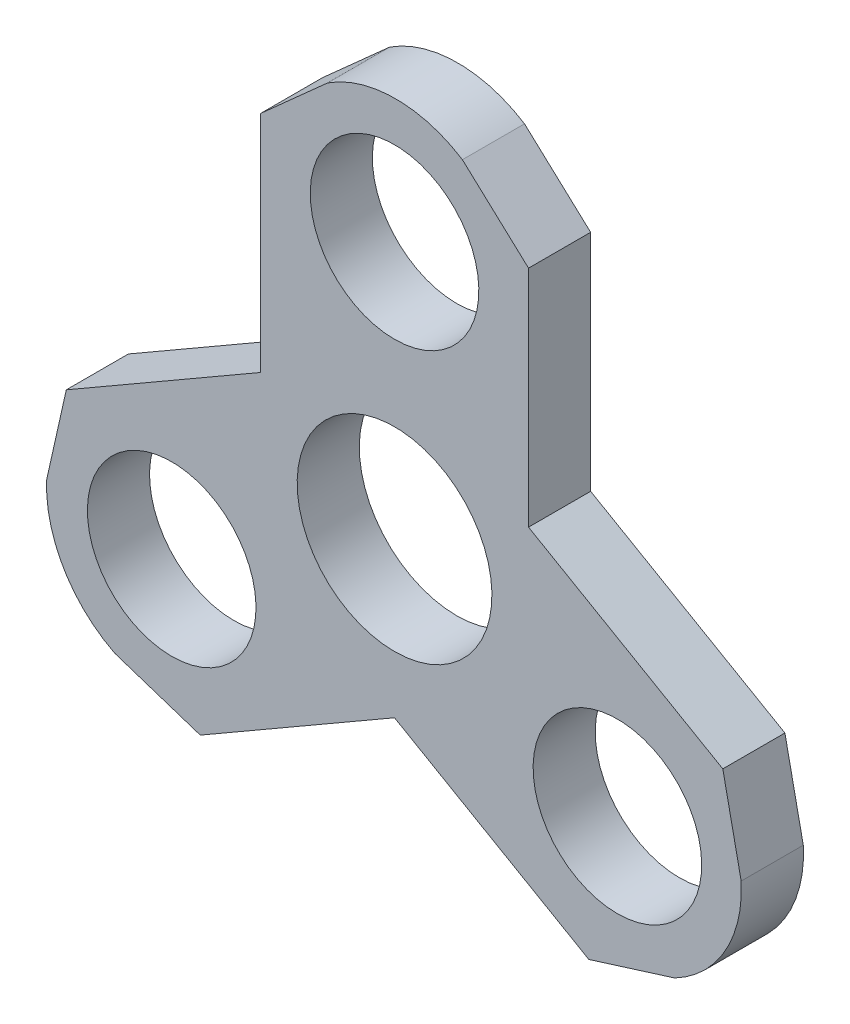
from build123d import *

# Parameters (mm, degrees)
SKETCH2_R             = 10.975
SKETCH2_R_2           = 9.5
BOSS_EXTRUDE1_DEPTH   = 7
BODY_MOVE_COPY2_ANGLE = 90


with BuildPart() as part:
    # Sketch2 → Boss-Extrude1 (new body)
    with BuildSketch(Plane(origin=(0, 0, 0), x_dir=(1, 0, 0), z_dir=(0, 1, 0))):
        with BuildLine():
            Line((15.1, 8.717989065), (15.1, 34))
            Line((15.1, 34), (7.646696155, 40.860405367))
            ThreePointArc((7.646696155, 40.860405367), (0.033272999, 43.046889297), (-7.548090014, 40.751707603))
            Line((-7.548090014, 40.751707603), (-15.1, 34))
            Line((-15.1, 34), (-15.1, 8.717989065))
            Line((-15.1, 8.717989065), (-36.994863729, -3.923016403))
            Line((-36.994863729, -3.923016403), (-39.209497135, -13.807969558))
            ThreePointArc((-39.209497135, -13.807969558), (-37.296336185, -21.494629386), (-31.517969025, -26.912691504))
            Line((-31.517969025, -26.912691504), (-21.894863729, -30.076983597))
            Line((-21.894863729, -30.076983597), (0, -17.43597813))
            Line((0, -17.43597813), (21.894863729, -30.076983597))
            Line((21.894863729, -30.076983597), (31.562800979, -27.052435809))
            ThreePointArc((31.562800979, -27.052435809), (37.263063186, -21.552259911), (39.066059039, -13.8390161))
            Line((39.066059039, -13.8390161), (36.994863729, -3.923016403))
            Line((36.994863729, -3.923016403), (15.1, 8.717989065))
        make_face()
        Circle(SKETCH2_R, mode=Mode.SUBTRACT)
        with Locations((0, 29)):
            Circle(SKETCH2_R_2, mode=Mode.SUBTRACT)
        with Locations((25.11473671, -14.5)):
            Circle(SKETCH2_R_2, mode=Mode.SUBTRACT)
        with Locations((-25.11473671, -14.5)):
            Circle(SKETCH2_R_2, mode=Mode.SUBTRACT)
    extrude(amount=BOSS_EXTRUDE1_DEPTH)


with BuildPart() as part_1:
    # Body-Move/Copy2: moved
    add(part.part.rotate(Axis((0, 3.5, -6.485131953), (1, 0, 0)), BODY_MOVE_COPY2_ANGLE))


solid = part_1.part
